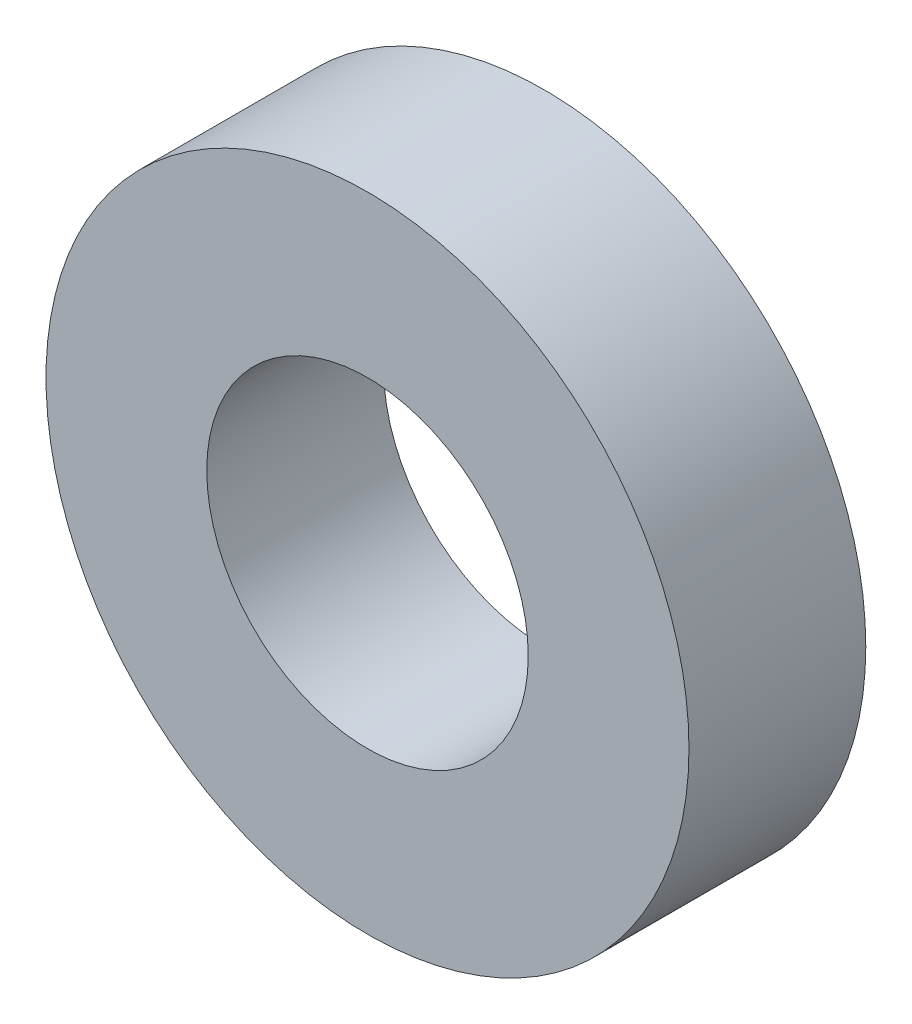
from build123d import *

# Parameters (mm, degrees)
SKETCH_1_R      = 10
SKETCH_1_R_2    = 5
EXTRUDE_1_DEPTH = 5.5


with BuildPart() as part:
    # 草图1 → 凸台-拉伸1 (new body)
    with BuildSketch(Plane.XY):
        Circle(SKETCH_1_R)
        Circle(SKETCH_1_R_2, mode=Mode.SUBTRACT)
    extrude(amount=EXTRUDE_1_DEPTH)


solid = part.part
